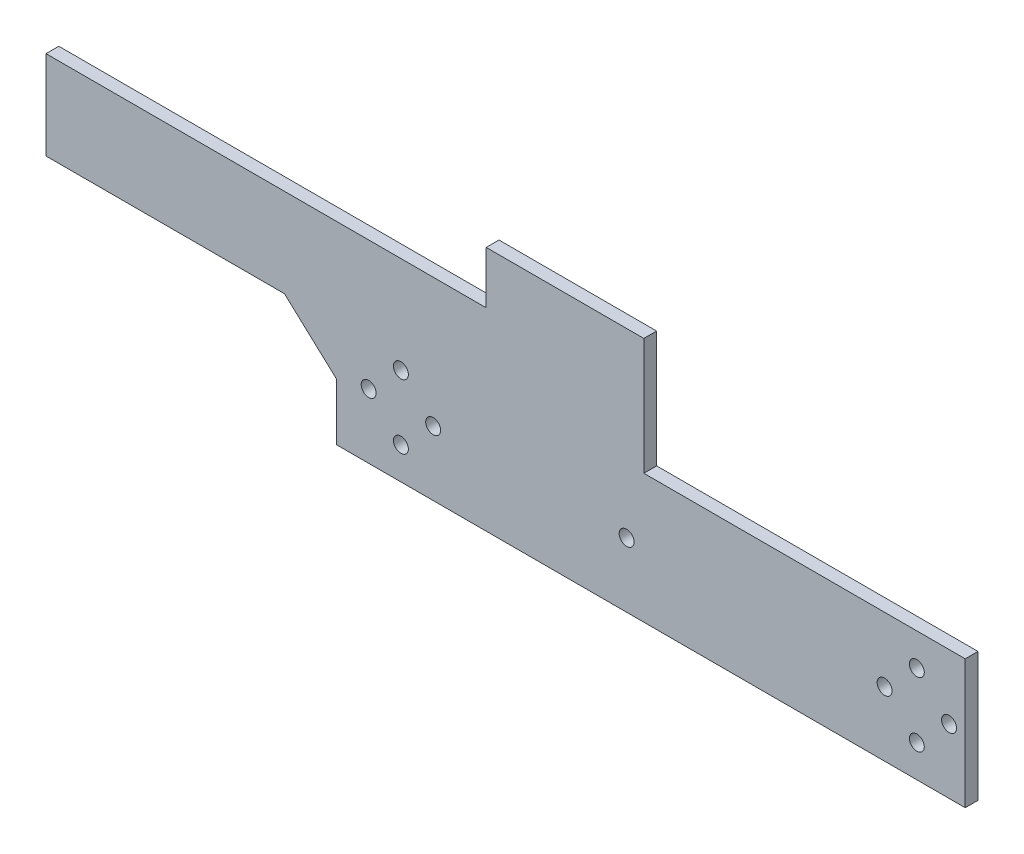
from build123d import *

# Parameters (mm, degrees)
SKETCH1_R           = 1.85
BOSS_EXTRUDE1_DEPTH = 3.175


with BuildPart() as part:
    # Sketch1 → Boss-Extrude1 (new body)
    with BuildSketch(Plane.XY):
        Polygon((156, 0), (0, 0), (0, 14.15), (-12.897437159, 26), (-72.0466, 26), (-72.0466, 48), (37.159, 48), (37.159, 60.975), (76.2722, 60.975), (76.2722, 32), (156, 32), align=None)
        with Locations((144, 8)):
            Circle(SKETCH1_R, mode=Mode.SUBTRACT)
        with Locations((144, 24)):
            Circle(SKETCH1_R, mode=Mode.SUBTRACT)
        with Locations((152, 16)):
            Circle(SKETCH1_R, mode=Mode.SUBTRACT)
        with Locations((136, 16)):
            Circle(SKETCH1_R, mode=Mode.SUBTRACT)
        with Locations((24, 16)):
            Circle(SKETCH1_R, mode=Mode.SUBTRACT)
        with Locations((16, 8)):
            Circle(SKETCH1_R, mode=Mode.SUBTRACT)
        with Locations((8, 16)):
            Circle(SKETCH1_R, mode=Mode.SUBTRACT)
        with Locations((16, 24)):
            Circle(SKETCH1_R, mode=Mode.SUBTRACT)
        with Locations((72, 16)):
            Circle(SKETCH1_R, mode=Mode.SUBTRACT)
    extrude(amount=BOSS_EXTRUDE1_DEPTH)


solid = part.part
